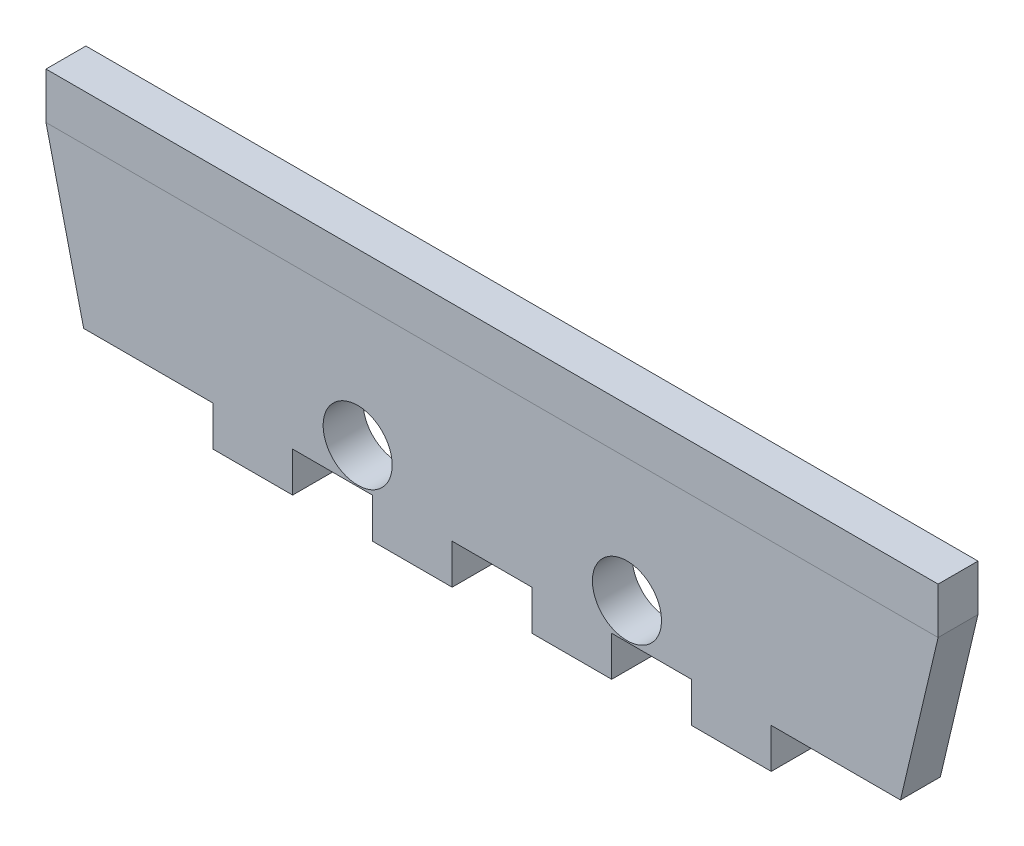
from build123d import *

# Parameters (mm, degrees)
SKETCH1_W           = 6.35
SKETCH1_H           = 3.175
BOSS_EXTRUDE1_DEPTH = 3.175
SKETCH2_W           = 56.563224847
SKETCH2_H           = 4.367971222
CUT_EXTRUDE2_DEPTH  = 10
SKETCH3_R           = 2.75
CUT_EXTRUDE3_DEPTH  = 3.175
SKETCH4_W           = 71.0184
SKETCH4_H           = 3.683
BOSS_EXTRUDE2_DEPTH = 3.175


with BuildPart() as part:
    # Sketch1 → Boss-Extrude1 (new body)
    with BuildSketch(Plane.XY):
        Polygon((10.287, 0), (0, 0), (-2.9972, 0), (0, -12.7), (10.287, -12.7), (16.637, -12.7), (22.987, -12.7), (29.337, -12.7), (35.687, -12.7), (42.037, -12.7), (48.387, -12.7), (54.737, -12.7), (65.024, -12.7), (68.0212, 0), (65.024, 0), (54.737, 0), (48.387, 0), (42.037, 0), (35.687, 0), (29.337, 0), (22.987, 0), (16.637, 0), align=None)
        with Locations((13.462, 1.5875)):
            Rectangle(SKETCH1_W, SKETCH1_H)
        with Locations((26.162, 1.5875)):
            Rectangle(SKETCH1_W, SKETCH1_H)
        with Locations((51.562, 1.5875)):
            Rectangle(SKETCH1_W, SKETCH1_H)
        with Locations((51.562, -14.2875)):
            Rectangle(SKETCH1_W, SKETCH1_H)
        with Locations((38.862, -14.2875)):
            Rectangle(SKETCH1_W, SKETCH1_H)
        with Locations((26.162, -14.2875)):
            Rectangle(SKETCH1_W, SKETCH1_H)
        with Locations((13.462, -14.2875)):
            Rectangle(SKETCH1_W, SKETCH1_H)
        with Locations((38.862, 1.5875)):
            Rectangle(SKETCH1_W, SKETCH1_H)
    extrude(amount=BOSS_EXTRUDE1_DEPTH)

    # Sketch2 → Cut-Extrude2 (cut)
    with BuildSketch(Plane.XY.offset(3.175)):
        with Locations((31.926512424, 2.183985611)):
            Rectangle(SKETCH2_W, SKETCH2_H)
    extrude(amount=-CUT_EXTRUDE2_DEPTH, mode=Mode.SUBTRACT)

    # Sketch3 → Cut-Extrude3 (cut)
    with BuildSketch(Plane(origin=(0, 0, 0), x_dir=(-1, 0, 0), z_dir=(0, 0, -1))):
        with Locations((-21.81296982, -9.8488)):
            Circle(SKETCH3_R)
        with Locations((-43.25056982, -9.8488)):
            Circle(SKETCH3_R)
    extrude(amount=-CUT_EXTRUDE3_DEPTH, mode=Mode.SUBTRACT)


with BuildPart() as body_2:
    # Sketch4 → Boss-Extrude2 (new body)
    with BuildSketch(Plane.XY.offset(3.175)):
        with Locations((32.512, 1.8415)):
            Rectangle(SKETCH4_W, SKETCH4_H)
    extrude(amount=-BOSS_EXTRUDE2_DEPTH)


solid = Compound([part.part, body_2.part])
